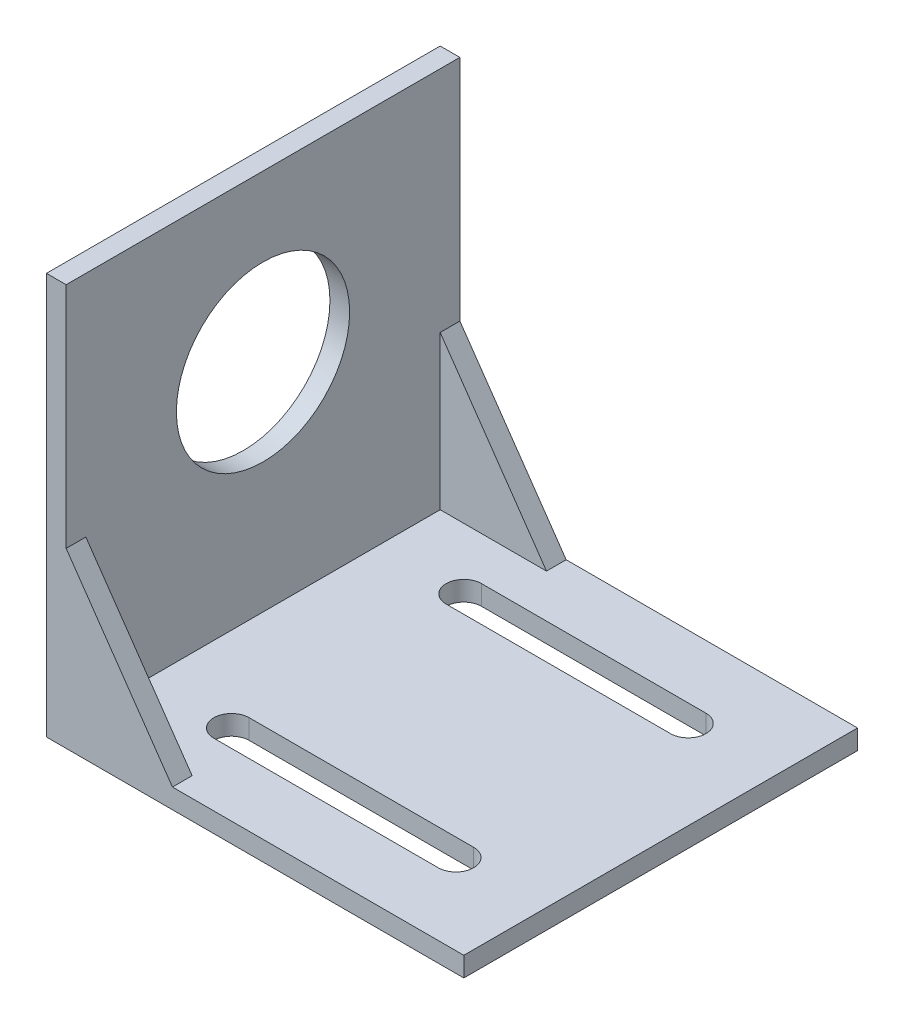
from build123d import *

# Parameters (mm, degrees)
BOSS_EXTRUDE1_DEPTH = 25
CUT_EXTRUDE1_DEPTH  = 10
SKETCH6_R           = 11
CUT_EXTRUDE2_DEPTH  = 10
BOSS_EXTRUDE2_DEPTH = 2.5


with BuildPart() as part:
    # Sketch1 → Boss-Extrude1 (new body, symmetric)
    with BuildSketch(Plane.XY):
        Polygon((53, 0), (0, 0), (0, 51), (2.5, 51), (2.5, 2.5), (53, 2.5), align=None)
    extrude(amount=BOSS_EXTRUDE1_DEPTH, both=True)

    # Sketch5 → Cut-Extrude1 (cut)
    with BuildSketch(Plane(origin=(0, 2.5, 0), x_dir=(1, 0, 0), z_dir=(0, 1, 0))):
        with BuildLine():
            Line((13.25, 17), (41.75, 17))
            ThreePointArc((41.75, 17), (44, 14.75), (41.75, 12.5))
            Line((41.75, 12.5), (13.25, 12.5))
            ThreePointArc((13.25, 12.5), (11, 14.75), (13.25, 17))
        make_face()
        with BuildLine():
            Line((13.25, -12.5), (41.75, -12.5))
            ThreePointArc((41.75, -12.5), (44, -14.75), (41.75, -17))
            Line((41.75, -17), (13.25, -17))
            ThreePointArc((13.25, -17), (11, -14.75), (13.25, -12.5))
        make_face()
    extrude(amount=-CUT_EXTRUDE1_DEPTH, mode=Mode.SUBTRACT)

    # Sketch6 → Cut-Extrude2 (cut)
    with BuildSketch(Plane(origin=(2.5, 0, 0), x_dir=(0, 0, -1), z_dir=(1, 0, 0))):
        with Locations((0, 30)):
            Circle(SKETCH6_R)
    extrude(amount=-CUT_EXTRUDE2_DEPTH, mode=Mode.SUBTRACT)

    # Sketch7 → Boss-Extrude2 (add)
    with BuildSketch(Plane.XY.offset(25)):
        Polygon((2.5, 22), (16, 2.5), (2.5, 2.5), align=None)
    boss_extrude2 = extrude(amount=-BOSS_EXTRUDE2_DEPTH)

    # Mirror1: Boss-Extrude2 across plane
    add(boss_extrude2.mirror(Plane.XY))


solid = part.part
